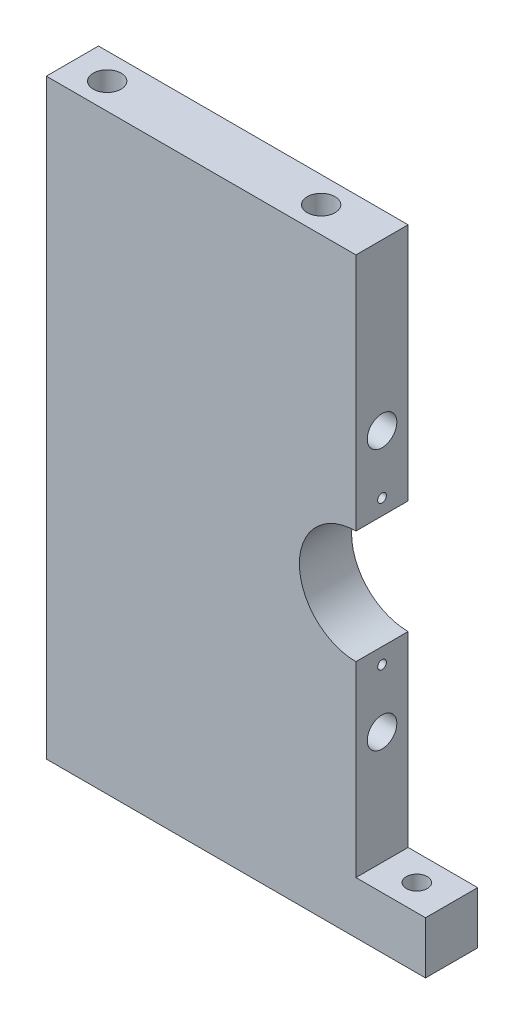
from build123d import *

# Parameters (mm, degrees)
BOSS_EXTRUDE1_DEPTH = 30
SKETCH2_R           = 8.5
CUT_EXTRUDE1_DEPTH  = 179
LPATTERN1_COUNT     = 2
LPATTERN1_PITCH     = 150
SKETCH3_R           = 2.5
CUT_EXTRUDE2_DEPTH  = 15
LPATTERN2_COUNT     = 2
LPATTERN2_PITCH     = 83
SKETCH4_R           = 6
CUT_EXTRUDE3_DEPTH  = 31
SKETCH5_R           = 8
CUT_EXTRUDE4_DEPTH  = 40


with BuildPart() as part:
    # Sketch1 → Boss-Extrude1 (new body)
    with BuildSketch(Plane.XY):
        with BuildLine():
            Line((0, 0), (0, 340))
            Line((0, 340), (178, 340))
            Line((178, 340), (178, 202.5))
            ThreePointArc((178, 202.5), (145.5, 170), (178, 137.5))
            Line((178, 137.5), (178, 30))
            Line((178, 30), (218, 30))
            Line((218, 30), (218, 0))
            Line((218, 0), (0, 0))
        make_face()
    extrude(amount=BOSS_EXTRUDE1_DEPTH)

    # Sketch2 → Cut-Extrude1 (cut, through all)
    with BuildSketch(Plane(origin=(178, 0, 0), x_dir=(0, 0, -1), z_dir=(1, 0, 0))):
        with Locations((-15, 95)):
            Circle(SKETCH2_R)
    cut_extrude1 = extrude(amount=-CUT_EXTRUDE1_DEPTH, mode=Mode.SUBTRACT)

    # LPattern1: Cut-Extrude1 ×2
    with Locations(*[(0, i * LPATTERN1_PITCH, 0) for i in range(1, LPATTERN1_COUNT)]):
        add(cut_extrude1, mode=Mode.SUBTRACT)

    # Sketch3 → Cut-Extrude2 (cut)
    with BuildSketch(Plane(origin=(178, 0, 0), x_dir=(0, 0, -1), z_dir=(1, 0, 0))):
        with Locations((-15, 128.5)):
            Circle(SKETCH3_R)
    cut_extrude2 = extrude(amount=-CUT_EXTRUDE2_DEPTH, mode=Mode.SUBTRACT)

    # LPattern2: Cut-Extrude2 ×2
    with Locations(*[(0, i * LPATTERN2_PITCH, 0) for i in range(1, LPATTERN2_COUNT)]):
        add(cut_extrude2, mode=Mode.SUBTRACT)

    # Sketch4 → Cut-Extrude3 (cut, through all)
    with BuildSketch(Plane(origin=(0, 30, 0), x_dir=(1, 0, 0), z_dir=(0, 1, 0))):
        with Locations((198, -15)):
            Circle(SKETCH4_R)
    extrude(amount=-CUT_EXTRUDE3_DEPTH, mode=Mode.SUBTRACT)

    # Sketch5 → Cut-Extrude4 (cut)
    with BuildSketch(Plane(origin=(0, 340, 0), x_dir=(1, 0, 0), z_dir=(0, 1, 0))):
        with Locations((20, -15)):
            Circle(SKETCH5_R)
        with Locations((143, -15)):
            Circle(SKETCH5_R)
    extrude(amount=-CUT_EXTRUDE4_DEPTH, mode=Mode.SUBTRACT)


solid = part.part
